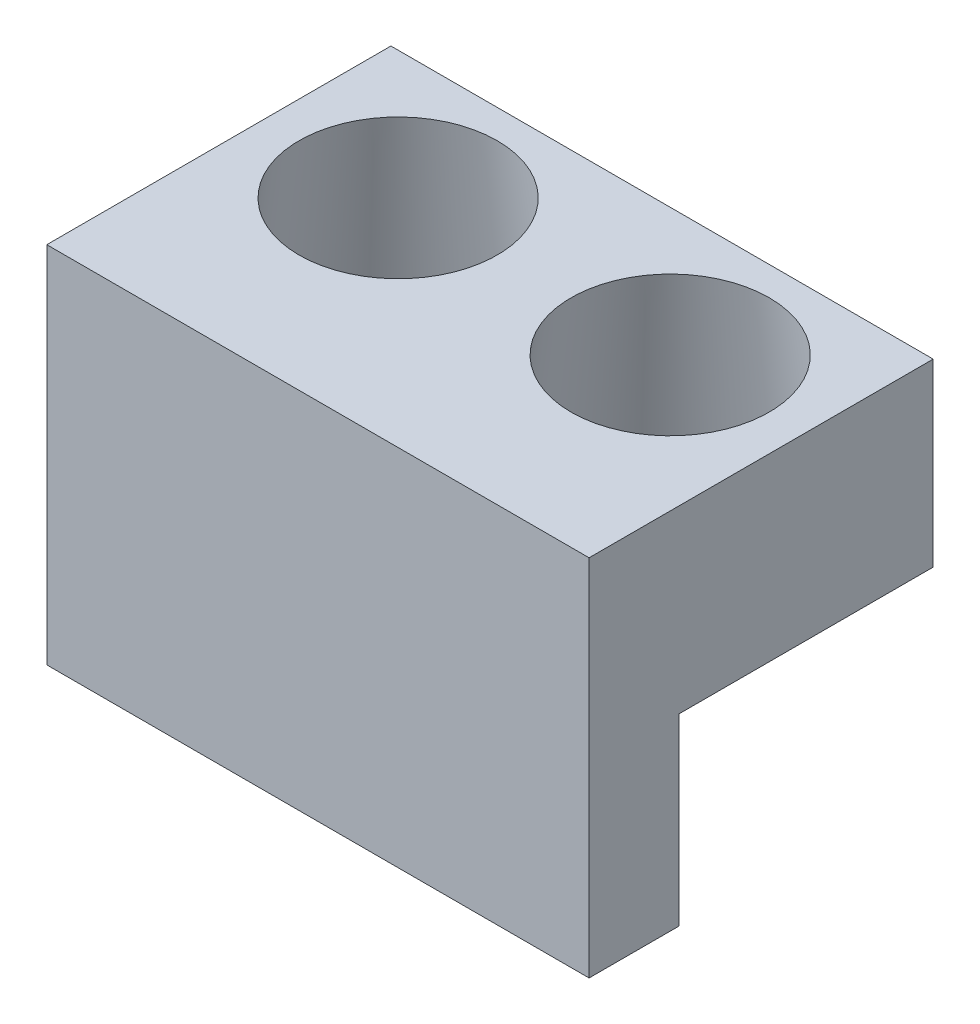
from build123d import *

# Parameters (mm, degrees)
SKETCH1_W           = 76.454
SKETCH1_H           = 12.7
BOSS_EXTRUDE1_DEPTH = 51.308
SKETCH2_W           = 76.454
SKETCH2_H           = 35.814
BOSS_EXTRUDE2_DEPTH = 25.4
SKETCH3_R           = 17.145
SKETCH4_R           = 13.97
SKETCH3_3_R         = 17.145
SKETCH4_3_R         = 13.97


with BuildPart() as part:
    # Sketch1 → Boss-Extrude1 (new body)
    with BuildSketch(Plane(origin=(0, 0, 0), x_dir=(1, 0, 0), z_dir=(0, 1, 0))):
        with Locations((0, -6.35)):
            Rectangle(SKETCH1_W, SKETCH1_H)
    extrude(amount=BOSS_EXTRUDE1_DEPTH)

    # Sketch2 → Boss-Extrude2 (add)
    with BuildSketch(Plane(origin=(0, 51.308, 0), x_dir=(1, 0, 0), z_dir=(0, 1, 0))):
        with Locations((0, 17.907)):
            Rectangle(SKETCH2_W, SKETCH2_H)
    extrude(amount=-BOSS_EXTRUDE2_DEPTH)

    # Sketch3 → Cut-Loft2 section 0
    with BuildSketch(Plane.XZ.offset(-25.908)):
        with Locations((19.177, -17.78)):
            Circle(SKETCH3_R)
    # Sketch4 → Cut-Loft2 section 1
    with BuildSketch(Plane(origin=(0, 51.308, 0), x_dir=(1, 0, 0), z_dir=(0, 1, 0))):
        with Locations((19.177, 17.78)):
            Circle(SKETCH4_R)
    loft(mode=Mode.SUBTRACT)

    # Sketch3_3 → Cut-Loft3 section 0
    with BuildSketch(Plane.XZ.offset(-25.908)):
        with Locations((-19.177, -17.78)):
            Circle(SKETCH3_3_R)
    # Sketch4_3 → Cut-Loft3 section 1
    with BuildSketch(Plane(origin=(0, 51.308, 0), x_dir=(1, 0, 0), z_dir=(0, 1, 0))):
        with Locations((-19.177, 17.78)):
            Circle(SKETCH4_3_R)
    loft(mode=Mode.SUBTRACT)


solid = part.part
